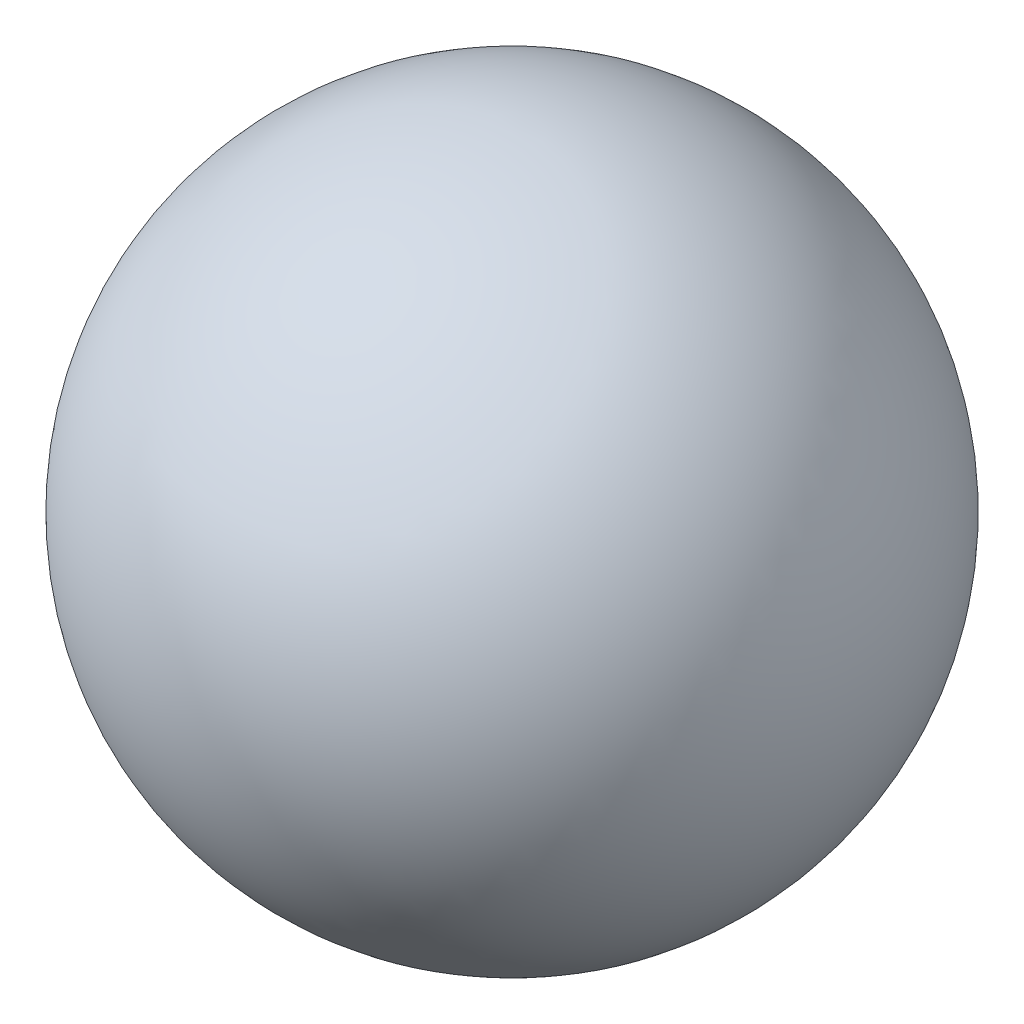
from build123d import *


with BuildPart() as part:
    # Esquisse1 → Révolution1 (revolve)
    with BuildSketch(Plane.XY):
        with BuildLine():
            Line((0, 40), (0, 0))
            ThreePointArc((0, 0), (-20, 20), (0, 40))
        make_face()
    revolve(axis=Axis((0, 51.249675259, 0), (0, -1, 0)))


solid = part.part
